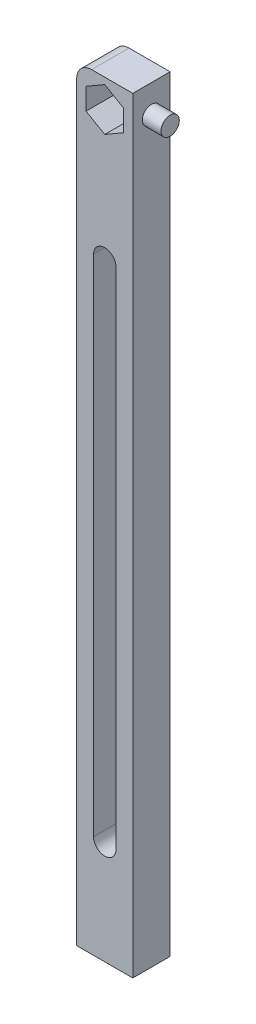
from build123d import *

# Parameters (mm, degrees)
CROQUIS1_W              = 220
CROQUIS1_H              = 220
CROQUIS1_W_2            = 190
CROQUIS1_H_2            = 190
SALIENTE_EXTRUIR1_DEPTH = 10
REDONDEO2_R             = 4
CORTAR_EXTRUIR4_DEPTH   = 10
CORTAR_EXTRUIR5_DEPTH   = 10
CROQUIS6_W              = 214.832400875
CROQUIS6_H              = 220
CORTAR_EXTRUIR6_DEPTH   = 10
CROQUIS7_R              = 2.45
SALIENTE_EXTRUIR2_DEPTH = 5
CROQUIS11_W             = 15
CROQUIS11_H             = 15
CORTAR_EXTRUIR9_DEPTH   = 10
CROQUIS12_R             = 2.5
CORTAR_EXTRUIR10_DEPTH  = 6


with BuildPart() as part:
    # Croquis1 → Saliente-Extruir1 (new body)
    with BuildSketch(Plane.XY):
        with Locations((110, -110)):
            Rectangle(CROQUIS1_W, CROQUIS1_H)
        with Locations((110, -110)):
            Rectangle(CROQUIS1_W_2, CROQUIS1_H_2, mode=Mode.SUBTRACT)
        Polygon((212.5, -13.273502692), (217.5, -10.386751346), (217.5, -4.613248654), (212.5, -1.726497308), (207.5, -4.613248654), (207.5, -10.386751346), align=None, mode=Mode.SUBTRACT)
        Polygon((7.5, -13.273502692), (12.5, -10.386751346), (12.5, -4.613248654), (7.5, -1.726497308), (2.5, -4.613248654), (2.5, -10.386751346), align=None, mode=Mode.SUBTRACT)
        Polygon((212.5, -218.273502692), (217.5, -215.386751346), (217.5, -209.613248654), (212.5, -206.726497308), (207.5, -209.613248654), (207.5, -215.386751346), align=None, mode=Mode.SUBTRACT)
        Polygon((7.5, -218.273502692), (12.5, -215.386751346), (12.5, -209.613248654), (7.5, -206.726497308), (2.5, -209.613248654), (2.5, -215.386751346), align=None, mode=Mode.SUBTRACT)
    extrude(amount=SALIENTE_EXTRUIR1_DEPTH)

    # Redondeo2
    redondeo2_edges = [part.edges().sort_by_distance(p)[0] for p in [
        (0, 0, 5),
        (220, 0, 5),
        (220, -220, 5),
        (0, -220, 5),
    ]]
    fillet(redondeo2_edges, radius=REDONDEO2_R)

    # Croquis4 → Cortar-Extruir4 (cut)
    with BuildSketch(Plane.XY.offset(10)):
        with BuildLine():
            Line((42.5, -4.5), (177.5, -4.5))
            ThreePointArc((177.5, -4.5), (180.5, -7.5), (177.5, -10.5))
            Line((177.5, -10.5), (42.5, -10.5))
            ThreePointArc((42.5, -10.5), (39.5, -7.5), (42.5, -4.5))
        make_face()
        with BuildLine():
            Line((42.5, -215.5), (177.5, -215.5))
            ThreePointArc((177.5, -215.5), (180.5, -212.5), (177.5, -209.5))
            Line((177.5, -209.5), (42.5, -209.5))
            ThreePointArc((42.5, -209.5), (39.5, -212.5), (42.5, -215.5))
        make_face()
    extrude(amount=-CORTAR_EXTRUIR4_DEPTH, mode=Mode.SUBTRACT)

    # Croquis5 → Cortar-Extruir5 (cut)
    with BuildSketch(Plane.XY.offset(10)):
        with BuildLine():
            Line((10.5, -42.5), (10.5, -177.5))
            ThreePointArc((10.5, -177.5), (7.5, -180.5), (4.5, -177.5))
            Line((4.5, -177.5), (4.5, -42.5))
            ThreePointArc((4.5, -42.5), (7.5, -39.5), (10.5, -42.5))
        make_face()
        with BuildLine():
            Line((209.5, -42.5), (209.5, -177.5))
            ThreePointArc((209.5, -177.5), (212.5, -180.5), (215.5, -177.5))
            Line((215.5, -177.5), (215.5, -42.5))
            ThreePointArc((215.5, -42.5), (212.5, -39.5), (209.5, -42.5))
        make_face()
    extrude(amount=-CORTAR_EXTRUIR5_DEPTH, mode=Mode.SUBTRACT)

    # Croquis6 → Cortar-Extruir6 (cut)
    with BuildSketch(Plane.XY.offset(10)):
        with Locations((122.416200438, -110)):
            Rectangle(CROQUIS6_W, CROQUIS6_H)
    extrude(amount=-CORTAR_EXTRUIR6_DEPTH, mode=Mode.SUBTRACT)

    # Croquis7 → Saliente-Extruir2 (add)
    with BuildSketch(Plane(origin=(15, 0, 0), x_dir=(0, 0, -1), z_dir=(1, 0, 0))):
        with Locations((-5, -7.5)):
            Circle(CROQUIS7_R)
    extrude(amount=SALIENTE_EXTRUIR2_DEPTH)

    # Croquis11 → Cortar-Extruir9 (cut)
    with BuildSketch(Plane.XY.offset(10)):
        with Locations((7.5, -212.5)):
            Rectangle(CROQUIS11_W, CROQUIS11_H)
    extrude(amount=-CORTAR_EXTRUIR9_DEPTH, mode=Mode.SUBTRACT)

    # Croquis12 → Cortar-Extruir10 (cut)
    with BuildSketch(Plane.XZ.offset(205)):
        with Locations((7.5, 5)):
            Circle(CROQUIS12_R)
    extrude(amount=-CORTAR_EXTRUIR10_DEPTH, mode=Mode.SUBTRACT)


solid = part.part
